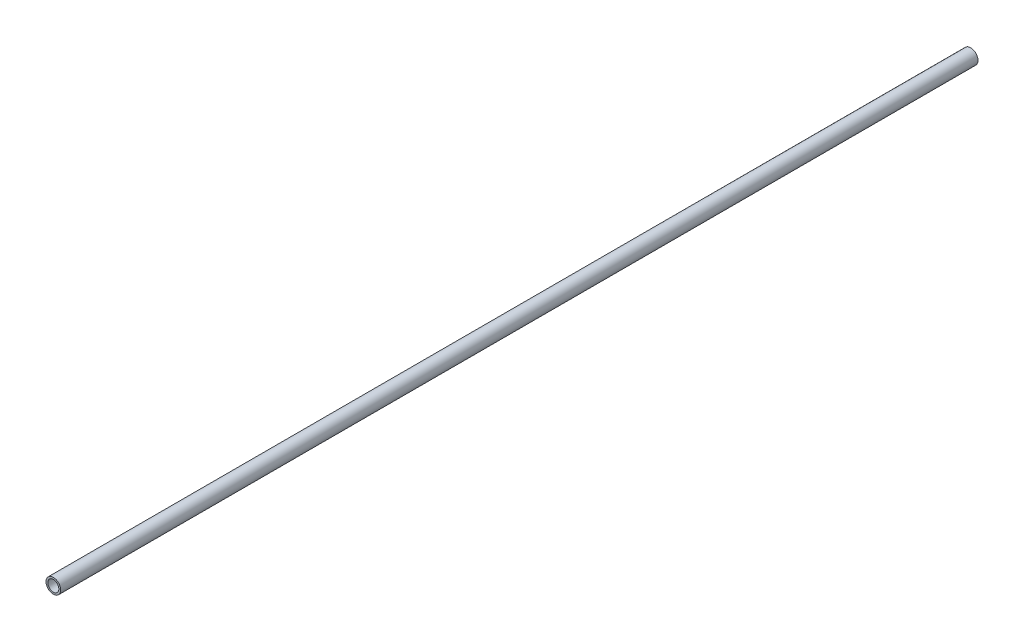
from build123d import *

# Parameters (mm, degrees)
SKETCH1_R           = 2
SKETCH1_R_2         = 1.5
BOSS_EXTRUDE1_DEPTH = 250


with BuildPart() as part:
    # Sketch1 → Boss-Extrude1 (new body)
    with BuildSketch(Plane.XY):
        Circle(SKETCH1_R)
        Circle(SKETCH1_R_2, mode=Mode.SUBTRACT)
    extrude(amount=BOSS_EXTRUDE1_DEPTH)


solid = part.part
